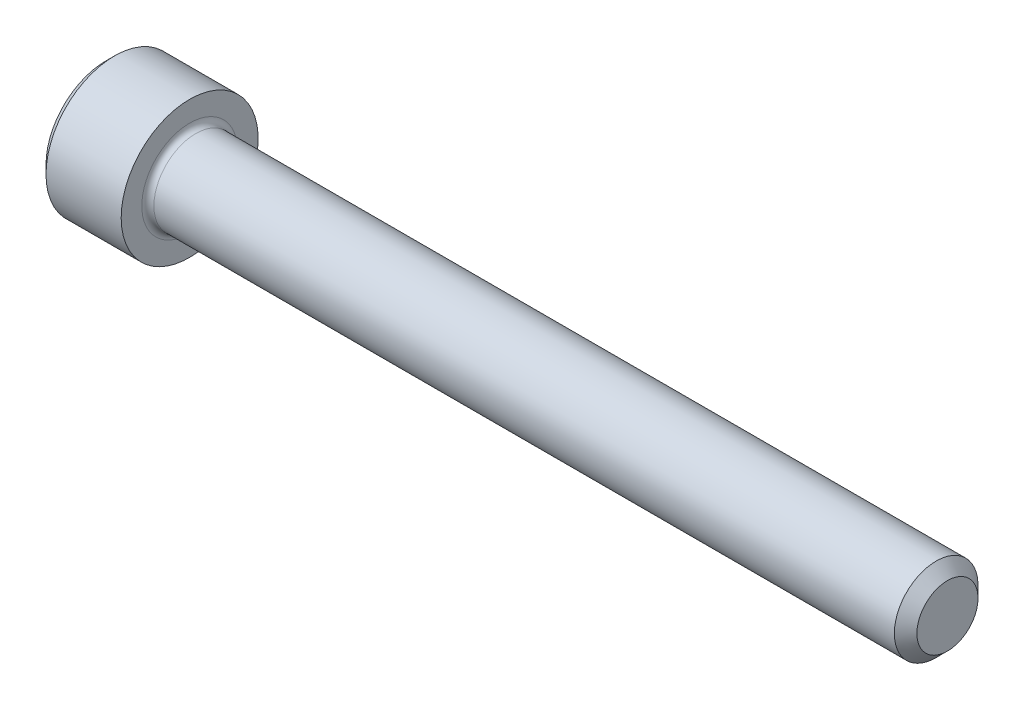
from build123d import *

# Parameters (mm, degrees)
FILLET1_R   = 0.254
HEX_2_DEPTH = 1.6256


with BuildPart() as part:
    # BodySke → Base-Revolve (revolve)
    with BuildSketch(Plane.XY):
        Polygon((0, 0), (0, 2.5146), (0.3556, 2.8702), (3.5052, 2.8702), (3.5052, 1.7526), (34.78276, 1.7526), (35.2552, 1.28016), (35.2552, 0), align=None)
    revolve(axis=Axis((-31.75, 0, 0), (1, 0, 0)))

    # Fillet1
    fillet1_edges = [part.edges().sort_by_distance(p)[0] for p in [
        (3.5052, -1.7526, 0),
    ]]
    fillet(fillet1_edges, radius=FILLET1_R)

    # Sketch2 → Hex-PreBroach (revolve, cut)
    with BuildSketch(Plane.XY):
        Polygon((0, 1.3843), (1.6256, 1.3843), (2.424825978, 0), (0, 0), align=None)
    revolve(axis=Axis((0, 0, 0), (1, 0, 0)), mode=Mode.SUBTRACT)

    # Sketch3 → Hex 2 (cut)
    with BuildSketch(Plane(origin=(0, 0, 0), x_dir=(0, 0.5, 0.866025404), z_dir=(-1, 0, 0))):
        Polygon((0.799225978, 1.3843), (-0.799225978, 1.3843), (-1.598451955, 0), (-0.799225978, -1.3843), (0.799225978, -1.3843), (1.598451955, 0), align=None)
    extrude(amount=-HEX_2_DEPTH, mode=Mode.SUBTRACT)


solid = part.part
